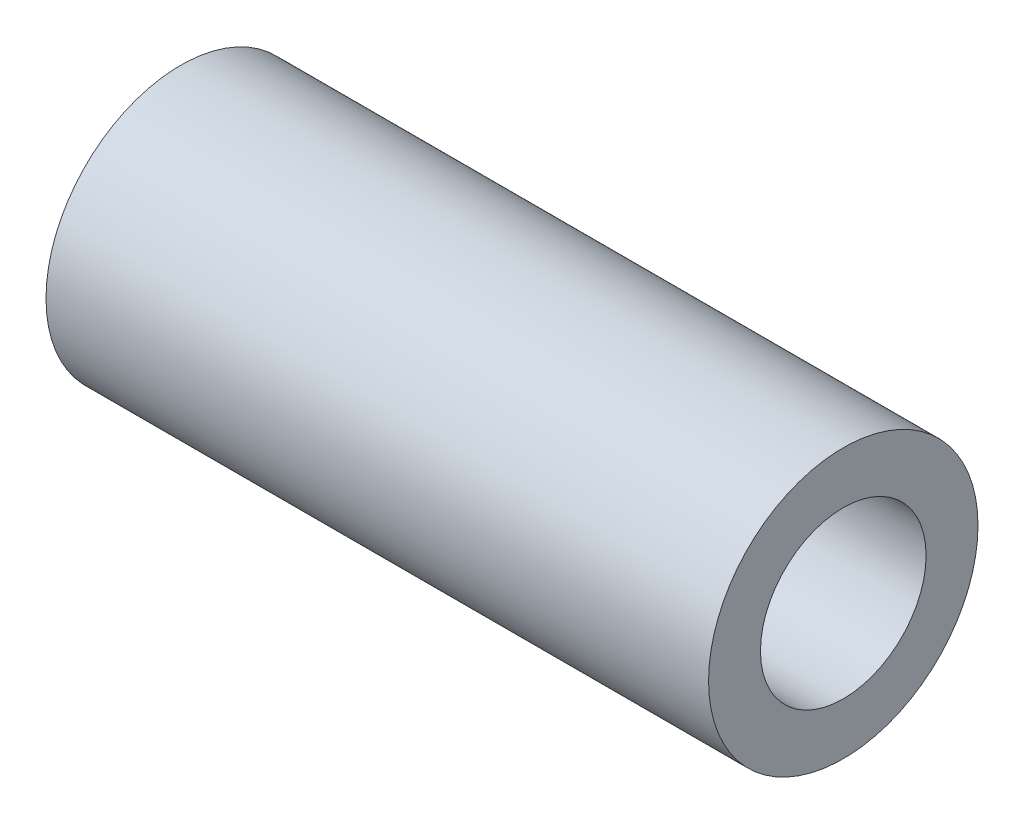
from build123d import *


with BuildPart() as part:
    # Sketch1 → Revolve1 (revolve)
    with BuildSketch(Plane(origin=(0, 0, 0), x_dir=(1, 0, 0), z_dir=(0, 1, 0))):
        Polygon((0, 0), (0, 3.8735), (19.05, 3.8735), (19.05, 2.38125), (12.7, 2.38125), (12.7, 0), align=None)
    revolve(axis=Axis((12.7, 0, 0), (-1, 0, 0)))


solid = part.part
